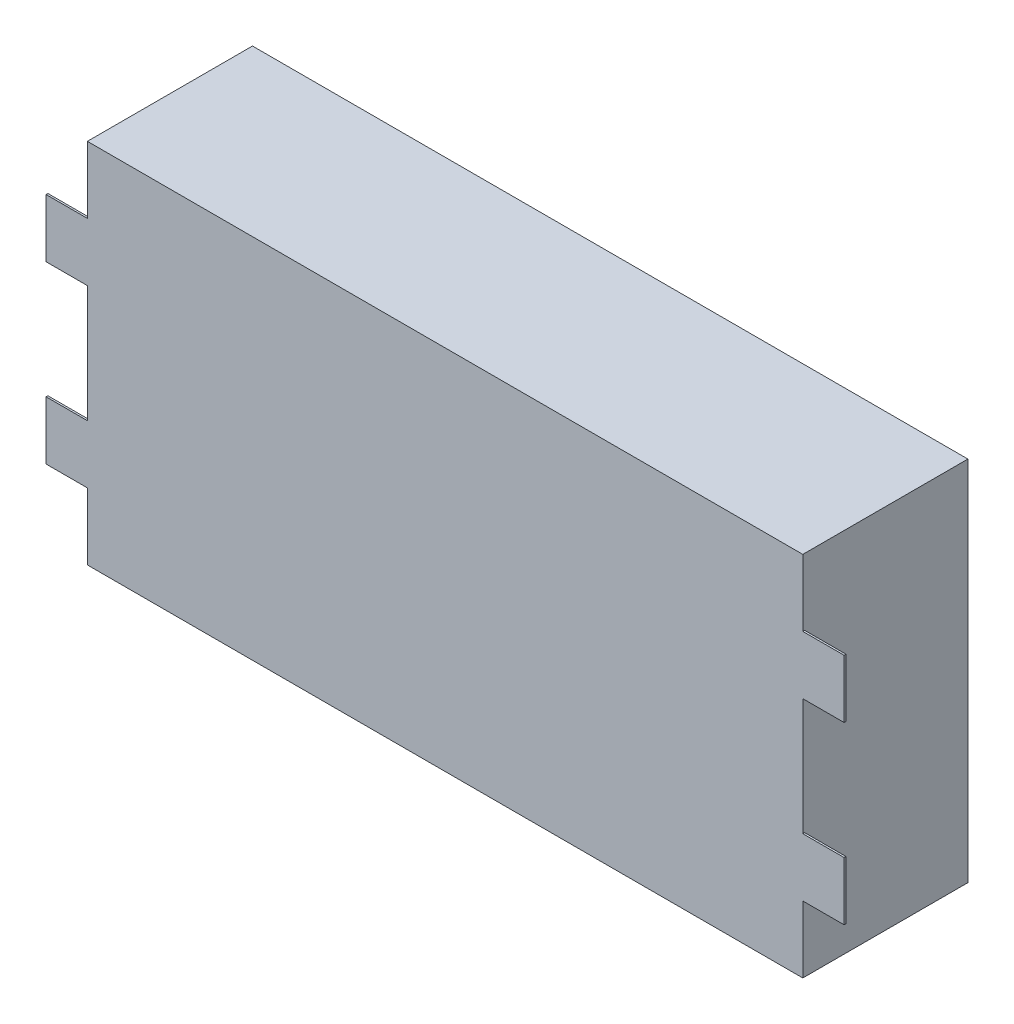
from build123d import *

# Parameters (mm, degrees)
SKETCH_1_W      = 78
SKETCH_1_H      = 40
EXTRUDE_1_DEPTH = 18
SKETCH_2_W      = 4.5
SKETCH_2_H      = 6.35
EXTRUDE_2_DEPTH = 0.2


with BuildPart() as part:
    # 草图1 → 凸台-拉伸1 (new body)
    with BuildSketch(Plane.XY):
        Rectangle(SKETCH_1_W, SKETCH_1_H)
    extrude(amount=EXTRUDE_1_DEPTH)

    # 草图2 → 凸台-拉伸2 (add)
    with BuildSketch(Plane.XY.offset(18)):
        with Locations((-41.25, 9.55)):
            Rectangle(SKETCH_2_W, SKETCH_2_H)
        with Locations((-41.25, -9.55)):
            Rectangle(SKETCH_2_W, SKETCH_2_H)
        with Locations((41.25, 9.55)):
            Rectangle(SKETCH_2_W, SKETCH_2_H)
        with Locations((41.25, -9.55)):
            Rectangle(SKETCH_2_W, SKETCH_2_H)
    extrude(amount=-EXTRUDE_2_DEPTH)


solid = part.part
